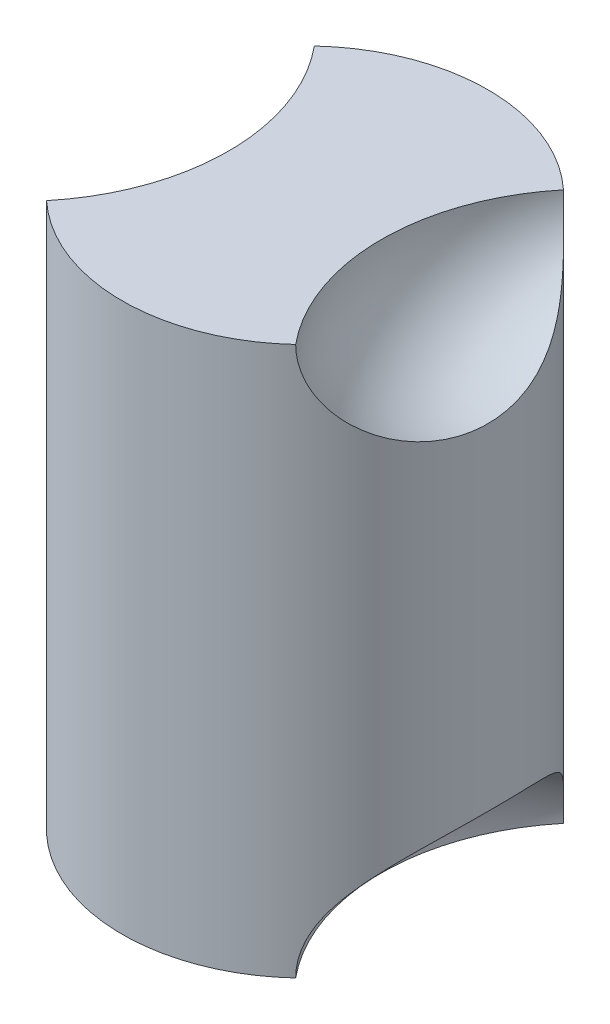
from build123d import *

# Parameters (mm, degrees)
SKETCH1_R           = 12.7
BOSS_EXTRUDE1_DEPTH = 38.1


with BuildPart() as part:
    # Sketch1 → Boss-Extrude1 (new body)
    with BuildSketch(Plane(origin=(0, 0, 0), x_dir=(1, 0, 0), z_dir=(0, 1, 0))):
        Circle(SKETCH1_R)
    extrude(amount=BOSS_EXTRUDE1_DEPTH)

    # Sketch2 → Cut-Revolve1 (revolve, cut)
    with BuildSketch(Plane(origin=(12.7, 0, 0), x_dir=(0, 0, -1), z_dir=(1, 0, 0))):
        with BuildLine():
            Line((-12.7, 38.1), (12.7, 38.1))
            ThreePointArc((12.7, 38.1), (0, 30.707213599), (-12.7, 38.1))
        make_face()
    revolve(axis=Axis((12.7, 38.1, 12.7), (0, 0, -1)), mode=Mode.SUBTRACT)

    # Sketch3 → Cut-Revolve2 (revolve, cut)
    with BuildSketch(Plane(origin=(12.7, 0, 0), x_dir=(0, 0, -1), z_dir=(1, 0, 0))):
        with BuildLine():
            Line((-12.7, 0), (12.7, 0))
            ThreePointArc((12.7, 0), (0, 7.392786401), (-12.7, 0))
        make_face()
    revolve(axis=Axis((12.7, 0, 12.7), (0, 0, -1)), mode=Mode.SUBTRACT)

    # Sketch4 → Cut-Revolve3 (revolve, cut)
    with BuildSketch(Plane(origin=(-12.7, 0, 0), x_dir=(0, 0, -1), z_dir=(1, 0, 0))):
        with BuildLine():
            Line((-12.7, 38.1), (12.7, 38.1))
            ThreePointArc((12.7, 38.1), (0, 30.707213599), (-12.7, 38.1))
        make_face()
    revolve(axis=Axis((-12.7, 38.1, 12.7), (0, 0, -1)), mode=Mode.SUBTRACT)

    # Sketch5 → Cut-Revolve4 (revolve, cut)
    with BuildSketch(Plane(origin=(-12.7, 0, 0), x_dir=(0, 0, -1), z_dir=(1, 0, 0))):
        with BuildLine():
            Line((-12.7, 0), (12.664915911, 0))
            ThreePointArc((12.664915911, 0), (-0.017542044, 7.361983694), (-12.7, 0))
        make_face()
    revolve(axis=Axis((-12.7, 0, 0), (0, 0, 1)), mode=Mode.SUBTRACT)


solid = part.part
